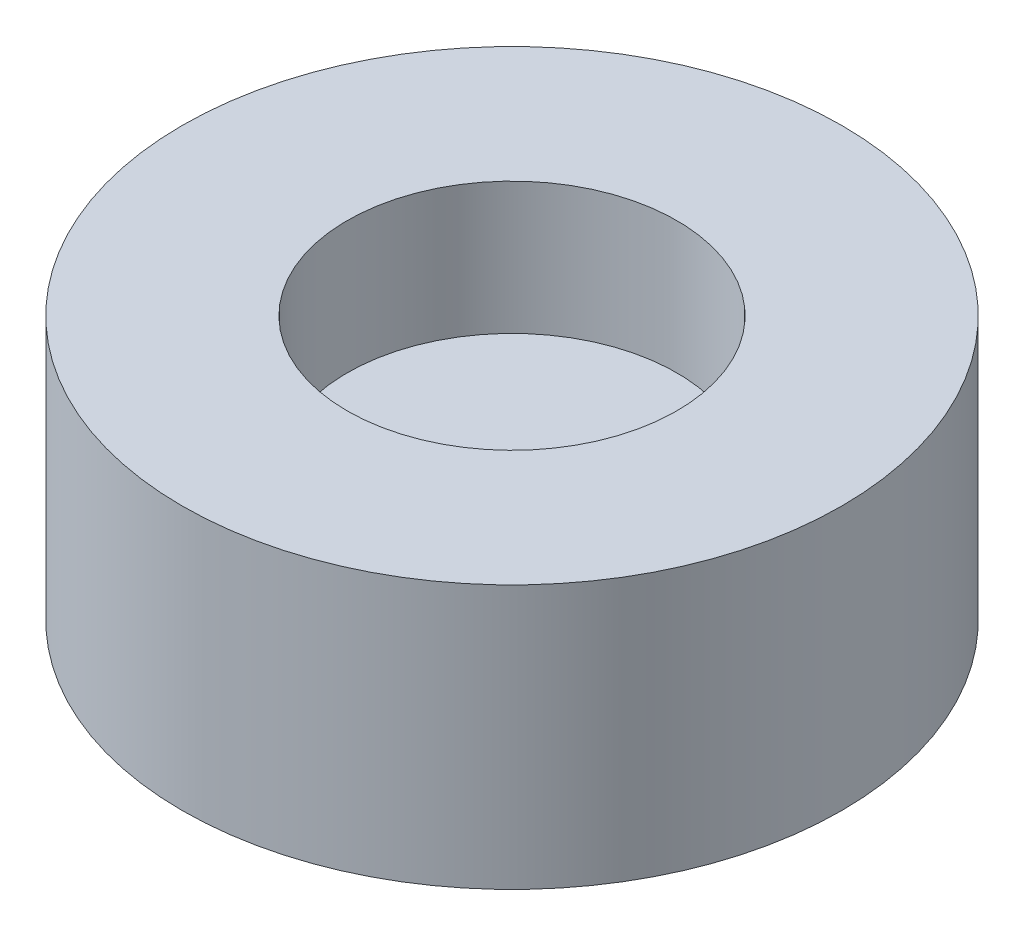
from build123d import *

# Parameters (mm, degrees)
SKETCH1_R           = 5
BOSS_EXTRUDE1_DEPTH = 4
SKETCH2_R           = 2.5
CUT_EXTRUDE1_DEPTH  = 2


with BuildPart() as part:
    # Sketch1 → Boss-Extrude1 (new body)
    with BuildSketch(Plane(origin=(0, 0, 0), x_dir=(1, 0, 0), z_dir=(0, 1, 0))):
        Circle(SKETCH1_R)
    extrude(amount=BOSS_EXTRUDE1_DEPTH)

    # Sketch2 → Cut-Extrude1 (cut)
    with BuildSketch(Plane(origin=(0, 4, 0), x_dir=(1, 0, 0), z_dir=(0, 1, 0))):
        Circle(SKETCH2_R)
    extrude(amount=-CUT_EXTRUDE1_DEPTH, mode=Mode.SUBTRACT)


solid = part.part
